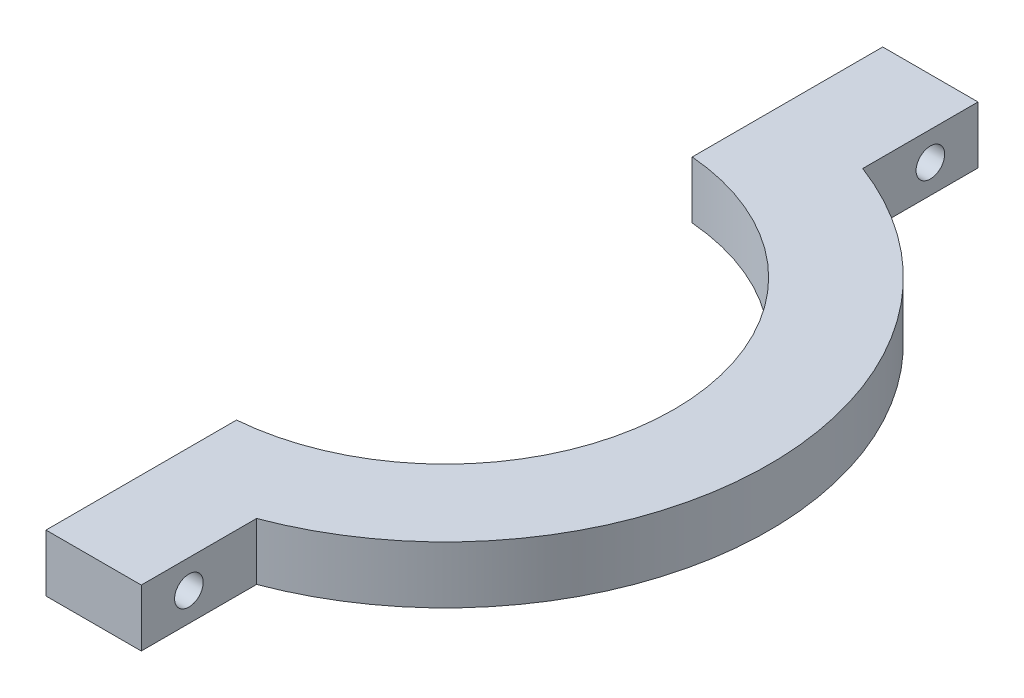
from build123d import *

# Parameters (mm, degrees)
BOSS_EXTRUDE1_DEPTH = 6
SKETCH4_R           = 1.5
CUT_EXTRUDE3_DEPTH  = 11


with BuildPart() as part:
    # Sketch1 → Boss-Extrude1 (new body)
    with BuildSketch(Plane(origin=(0, 0, 0), x_dir=(1, 0, 0), z_dir=(0, 1, 0))):
        with BuildLine():
            Line((2, 43.916521486), (2, 23.916521486))
            ThreePointArc((2, 23.916521486), (24, 0), (2, -23.916521486))
            Line((2, -23.916521486), (2, -43.916521486))
            Line((2, -43.916521486), (12, -43.916521486))
            Line((12, -43.916521486), (12, -31.811947441))
            ThreePointArc((12, -31.811947441), (28.791009913, -18.085290934), (33.867388444, 3))
            ThreePointArc((33.867388444, 3), (27.082954224, 20.55513538), (12, 31.811947441))
            Line((12, 31.811947441), (12, 43.916521486))
            Line((12, 43.916521486), (2, 43.916521486))
        make_face()
    extrude(amount=BOSS_EXTRUDE1_DEPTH)

    # Sketch4 → Cut-Extrude3 (cut, through all)
    with BuildSketch(Plane(origin=(12, 0, 0), x_dir=(0, 0, -1), z_dir=(1, 0, 0))):
        with Locations((-38.916521486, 3)):
            Circle(SKETCH4_R)
    cut_extrude3 = extrude(amount=-CUT_EXTRUDE3_DEPTH, mode=Mode.SUBTRACT)

    # Mirror1: Cut-Extrude3 across plane
    add(cut_extrude3.mirror(Plane.XY), mode=Mode.SUBTRACT)


solid = part.part
